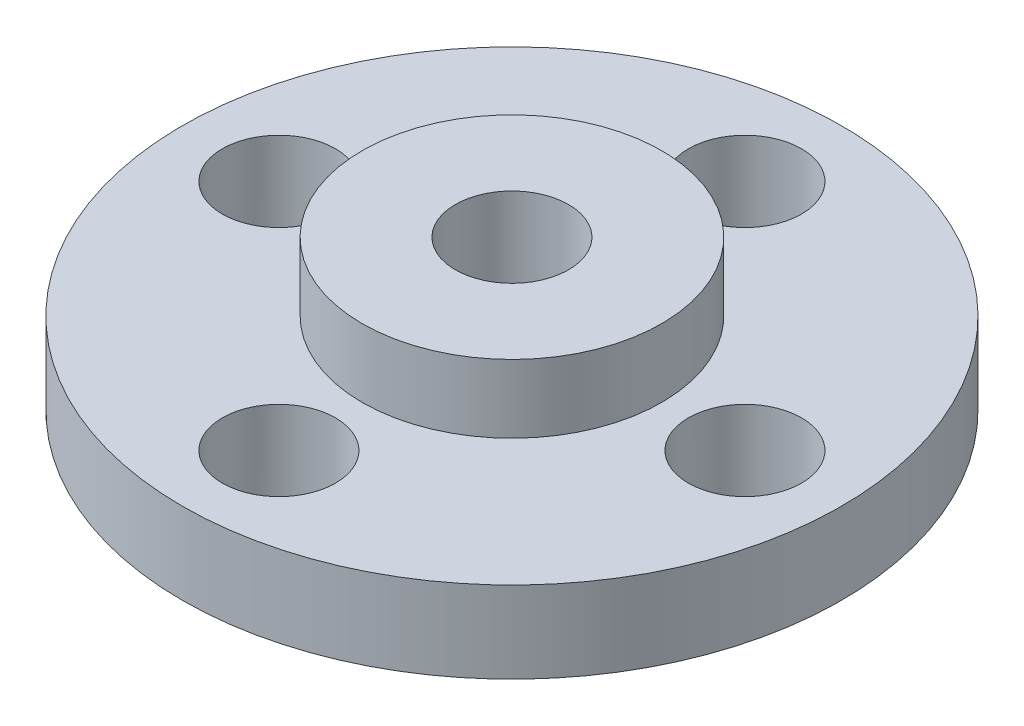
from build123d import *

# Parameters (mm, degrees)
SKETCH2_R            = 9.9
BOSS_EXTRUDE1_DEPTH  = 1.225
SKETCH3_R            = 4.5
BOSS_EXTRUDE2_DEPTH  = 2.05
M3_CLEARANCE_HOLE1_D = 3.4


with BuildPart() as part:
    # Sketch2 → Boss-Extrude1 (new body, symmetric)
    with BuildSketch(Plane(origin=(0, 0, 0), x_dir=(1, 0, 0), z_dir=(0, 1, 0))):
        Circle(SKETCH2_R)
    extrude(amount=BOSS_EXTRUDE1_DEPTH, both=True)

    # Sketch3 → Boss-Extrude2 (add)
    with BuildSketch(Plane(origin=(0, 1.225, 0), x_dir=(1, 0, 0), z_dir=(0, 1, 0))):
        Circle(SKETCH3_R)
    extrude(amount=BOSS_EXTRUDE2_DEPTH)

    # M3 Clearance Hole1 (through all)
    with Locations(Plane(origin=(0, -1.225, 0), x_dir=(-1, 0, 0), z_dir=(0, -1, 0))):
        with Locations((0, 0), (0, 7), (7, 0), (0, -7), (-7, 0)):
            Hole(M3_CLEARANCE_HOLE1_D / 2)


solid = part.part
